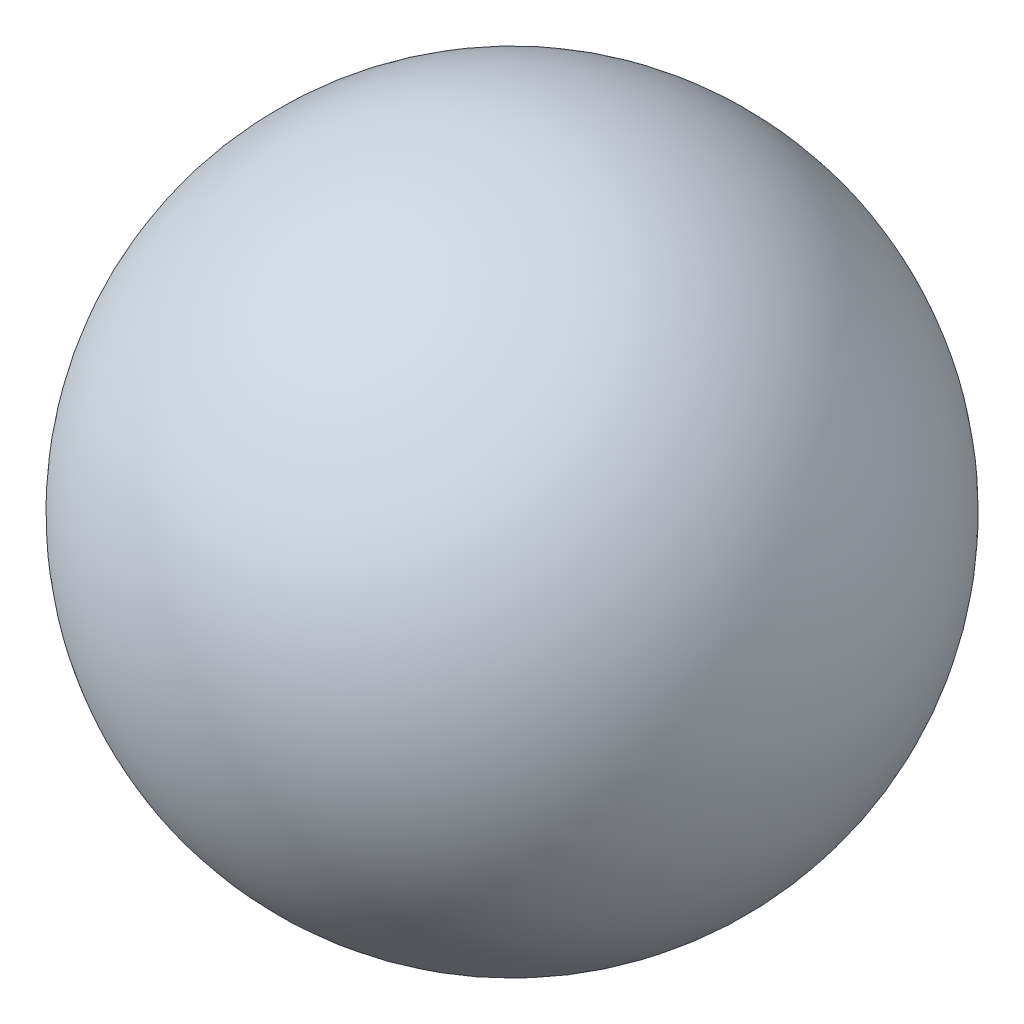
from build123d import *


with BuildPart() as part:
    # Sketch1 → Revolve1 (revolve)
    with BuildSketch(Plane(origin=(0, 0, 0), x_dir=(1, 0, 0), z_dir=(0, 1, 0))):
        with BuildLine():
            Line((0, 4), (0, -4))
            ThreePointArc((0, -4), (4, 0), (0, 4))
        make_face()
    revolve(axis=Axis((0, 0, 4), (0, 0, -1)))


solid = part.part
